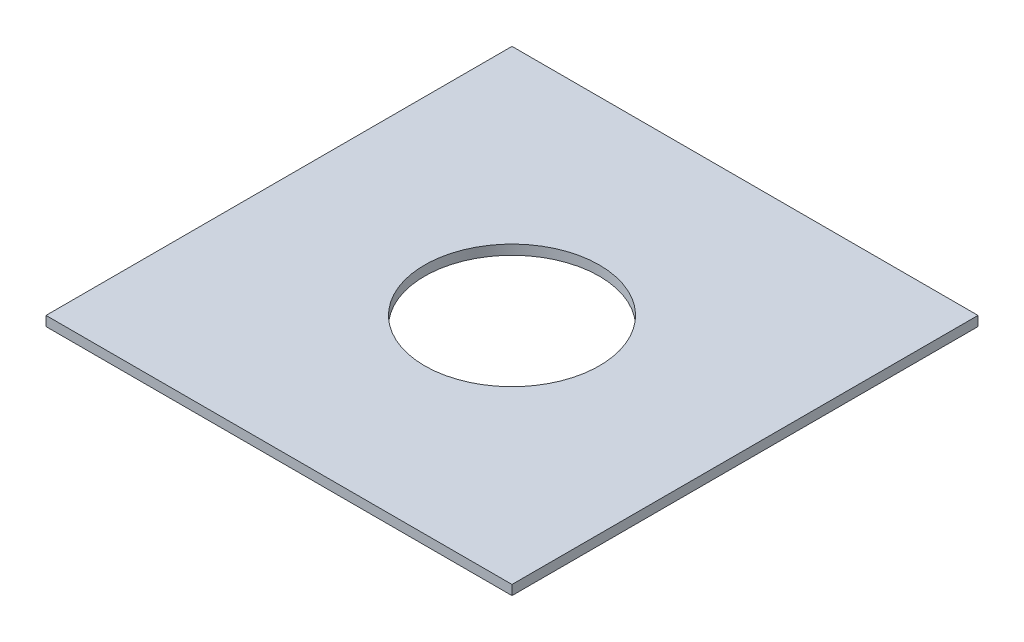
from build123d import *

# Parameters (mm, degrees)
SKETCH1_W           = 304.8
SKETCH1_H           = 304.8
BOSS_EXTRUDE1_DEPTH = 6.35
CUT_EXTRUDE1_REACH  = 8.35
SKETCH2_R           = 57.15


with BuildPart() as part:
    # Sketch1 → Boss-Extrude1 (new body)
    with BuildSketch(Plane(origin=(0, 0, 0), x_dir=(1, 0, 0), z_dir=(0, 1, 0))):
        with Locations((0, 152.4)):
            Rectangle(SKETCH1_W, SKETCH1_H)
    extrude(amount=BOSS_EXTRUDE1_DEPTH)

    # Sketch2 → Cut-Extrude1 (cut, up to next)
    with BuildSketch(Plane(origin=(0, 6.35, 0), x_dir=(1, 0, 0), z_dir=(0, 1, 0)), mode=Mode.PRIVATE) as cut_extrude1_sk1:
        with Locations((0, 152.4)):
            Circle(SKETCH2_R)
    cut_extrude1_tool1 = extrude(cut_extrude1_sk1.sketch, amount=-CUT_EXTRUDE1_REACH, mode=Mode.PRIVATE) & part.part
    add(cut_extrude1_tool1.solids().sort_by_distance((0, 6.35, -152.4))[0], mode=Mode.SUBTRACT)


solid = part.part
